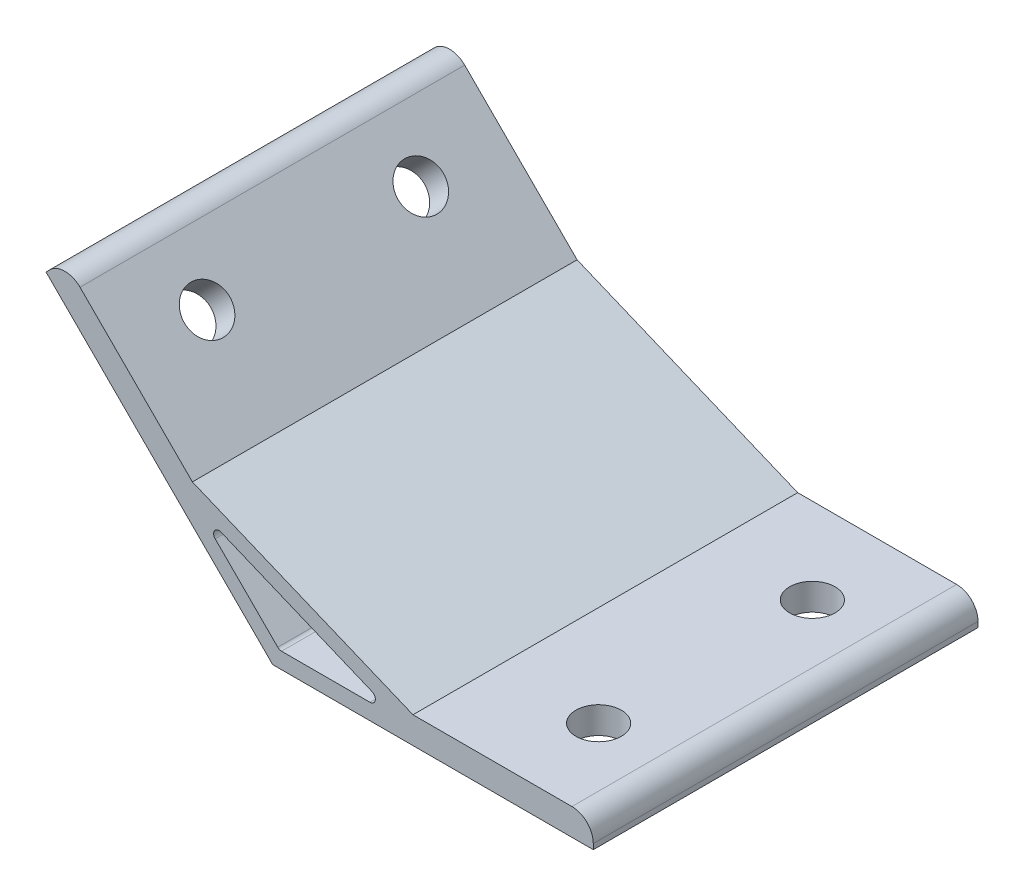
from build123d import *

# Parameters (mm, degrees)
EXTRUDE_1_DEPTH     = 36
SKETCH_2_R          = 4.25
CUT_EXTRUDE_1_DEPTH = 5
SKETCH_3_R          = 4.25
CUT_EXTRUDE_2_DEPTH = 5
FILLET_1_R          = 4
FILLET_2_R          = 1


with BuildPart() as part:
    # Эскиз1 → Бобышка-Вытянуть1 (new body, symmetric)
    with BuildSketch(Plane.XY):
        Polygon((0, 0), (-42.426406871, 42.426406871), (-38.890872965, 45.961940777), (-15.028558569, 22.099626381), (26.253591352, 5), (60, 5), (60, 0), align=None)
        Polygon((-14.313708499, 18.556349186), (23.242640687, 3), (1.242640687, 3), align=None, mode=Mode.SUBTRACT)
    extrude(amount=EXTRUDE_1_DEPTH, both=True)

    # Эскиз2 → Вырез-Вытянуть1 (cut)
    with BuildSketch(Plane(origin=(0, 0, 0), x_dir=(0, 0, 1), z_dir=(-0.707106781, -0.707106781, 0))):
        with Locations(Location((-20, 45, 0), (0, 0, 270))):  # turned: the seam where the file's is
            Circle(SKETCH_2_R)
        with Locations(Location((20, 45, 0), (0, 0, 270))):  # turned: the seam where the file's is
            Circle(SKETCH_2_R)
    extrude(amount=-CUT_EXTRUDE_1_DEPTH, mode=Mode.SUBTRACT)

    # Эскиз3 → Вырез-Вытянуть2 (cut)
    with BuildSketch(Plane.XZ):
        with Locations(Location((45, 20, 0), (0, 0, 270))):  # turned: the seam where the file's is
            Circle(SKETCH_3_R)
        with Locations(Location((45, -20, 0), (0, 0, 270))):  # turned: the seam where the file's is
            Circle(SKETCH_3_R)
    extrude(amount=-CUT_EXTRUDE_2_DEPTH, mode=Mode.SUBTRACT)

    # Скругление1
    fillet_1_edges = [part.edges().sort_by_distance(p)[0] for p in [
        (-38.890872965, 45.961940777, 0),
        (60, 5, 0),
    ]]
    fillet(fillet_1_edges, radius=FILLET_1_R)

    # Скругление2
    fillet_2_edges = [part.edges().sort_by_distance(p)[0] for p in [
        (-14.313708499, 18.556349186, 0),
        (1.242640687, 3, 0),
        (23.242640687, 3, 0),
    ]]
    fillet(fillet_2_edges, radius=FILLET_2_R)


solid = part.part
